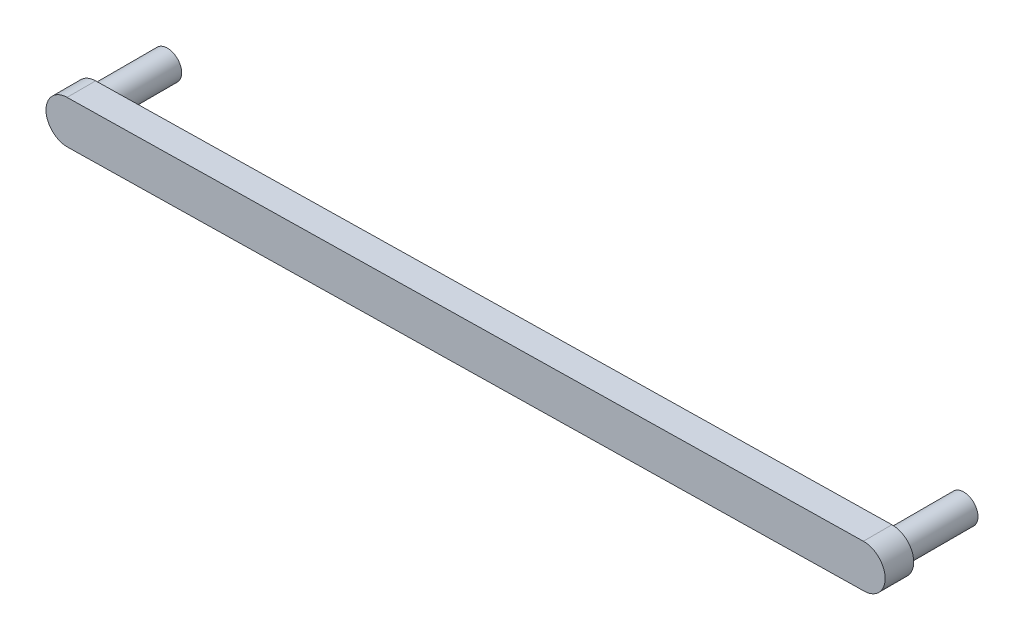
from build123d import *

# Parameters (mm, degrees)
BOSS_EXTRUDE1_DEPTH = 2
SKETCH1_3_R         = 1
BOSS_EXTRUDE2_DEPTH = 5


with BuildPart() as part:
    # Sketch1 → Boss-Extrude1 (new body)
    with BuildSketch(Plane.XY):
        with BuildLine():
            Line((-0.025909327, -13.500223781), (55.727261904, -12.537061992))
            ThreePointArc((55.727261904, -12.537061992), (57.25294745, -14.010928883), (55.779080559, -15.536614429))
            Line((55.779080559, -15.536614429), (0.025909327, -16.499776219))
            ThreePointArc((0.025909327, -16.499776219), (-1.499776219, -15.025909327), (-0.025909327, -13.500223781))
        make_face()
    extrude(amount=BOSS_EXTRUDE1_DEPTH)

    # Sketch1_3 → Boss-Extrude2 (add)
    with BuildSketch(Plane.XY):
        with Locations((0, -15)):
            Circle(SKETCH1_3_R)
        with Locations((55.753171232, -14.03683821)):
            Circle(SKETCH1_3_R)
    extrude(amount=-BOSS_EXTRUDE2_DEPTH)


solid = part.part
